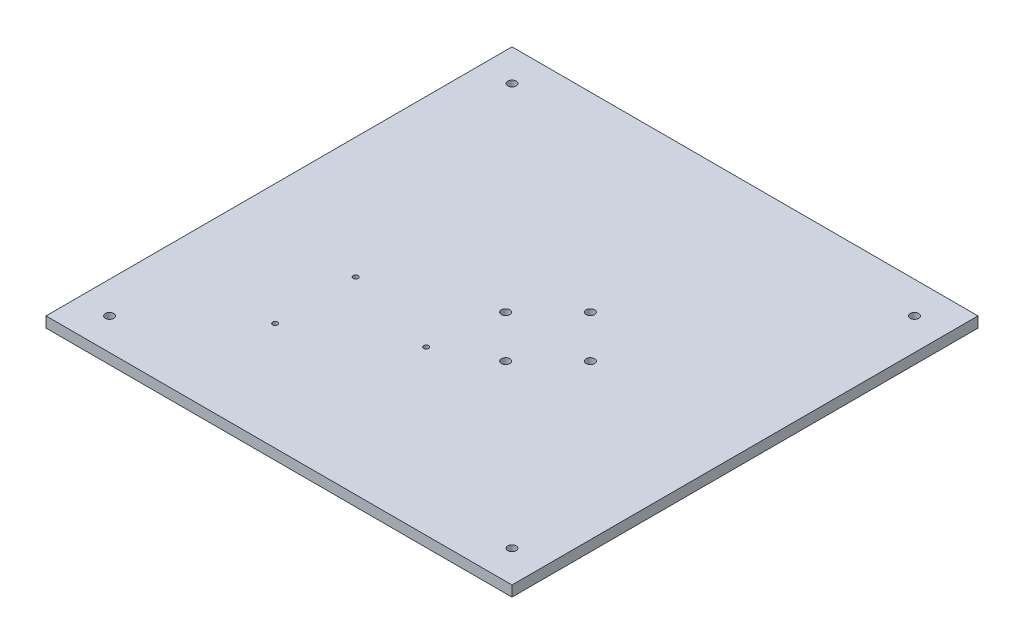
from build123d import *

# Parameters (mm, degrees)
SKETCH1_W                = 279.4
SKETCH1_H                = 279.4
BASE_EXTRUSION_DEPTH     = 6.35
SKETCH2_R                = 2.54
CONSTRUCTION_HOLES_DEPTH = 6.35
SKETCH3_R                = 1.5
BOARD_HOLES_DEPTH        = 127
SKETCH4_R                = 2.54
MOTOR_HOLES_DEPTH        = 36.576


with BuildPart() as part:
    # Sketch1 → base_extrusion (new body)
    with BuildSketch(Plane(origin=(0, 0, 0), x_dir=(1, 0, 0), z_dir=(0, 1, 0))):
        with Locations((13.106864989, 14.705263158)):
            Rectangle(SKETCH1_W, SKETCH1_H)
    extrude(amount=BASE_EXTRUSION_DEPTH)

    # Sketch2 → construction_holes (cut)
    with BuildSketch(Plane(origin=(0, 6.35, 0), x_dir=(1, 0, 0), z_dir=(0, 1, 0))):
        with Locations((-107.543135011, 135.355263158)):
            Circle(SKETCH2_R)
        with Locations((133.756864989, 135.355263158)):
            Circle(SKETCH2_R)
        with Locations((133.756864989, -105.944736842)):
            Circle(SKETCH2_R)
        with Locations((-107.543135011, -105.944736842)):
            Circle(SKETCH2_R)
    extrude(amount=-CONSTRUCTION_HOLES_DEPTH, mode=Mode.SUBTRACT)

    # Sketch3 → board holes (cut)
    with BuildSketch(Plane(origin=(0, 6.35, 0), x_dir=(1, 0, 0), z_dir=(0, 1, 0))):
        with Locations((3.556864989, -27.204736715)):
            Circle(SKETCH3_R)
        with Locations((-53.983135011, -60.224736819)):
            Circle(SKETCH3_R)
        with Locations((-53.983135011, -11.964736865)):
            Circle(SKETCH3_R)
    extrude(amount=-BOARD_HOLES_DEPTH, mode=Mode.SUBTRACT)

    # Sketch4 → motor holes (cut)
    with BuildSketch(Plane(origin=(0, 6.35, 0), x_dir=(1, 0, 0), z_dir=(0, 1, 0))):
        with Locations((34.696864989, 40.105263158)):
            Circle(SKETCH4_R)
        with Locations((60.096864989, 14.705263158)):
            Circle(SKETCH4_R)
        with Locations((34.696864989, -10.694736842)):
            Circle(SKETCH4_R)
        with Locations((9.296864989, 14.705263158)):
            Circle(SKETCH4_R)
    extrude(amount=-MOTOR_HOLES_DEPTH, mode=Mode.SUBTRACT)


solid = part.part
